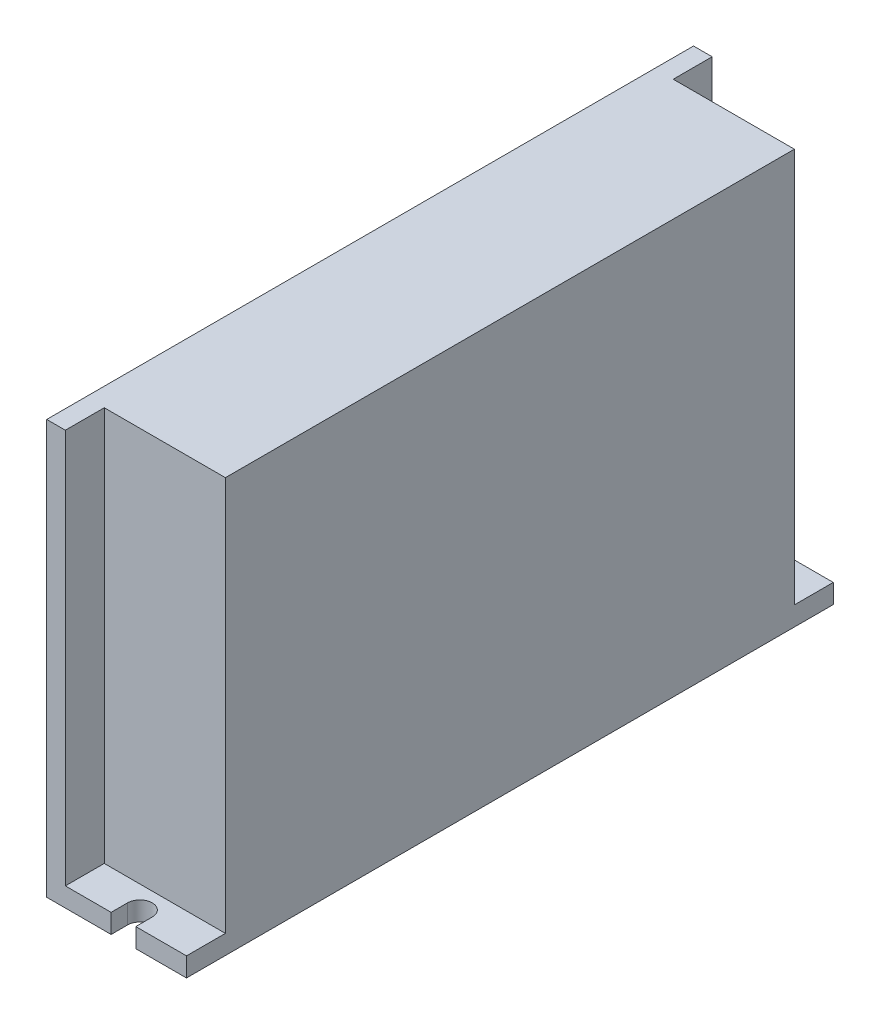
from build123d import *

# Parameters (mm, degrees)
SKETCH2_W           = 25.5
SKETCH2_H           = 118
BOSS_EXTRUDE3_DEPTH = 3.5
CUT_EXTRUDE1_DEPTH  = 4.5
SKETCH4_W           = 3.4
SKETCH4_H           = 118
BOSS_EXTRUDE4_DEPTH = 72
SKETCH5_W           = 22.1
SKETCH5_H           = 103.8
BOSS_EXTRUDE5_DEPTH = 72


with BuildPart() as part:
    # Sketch2 → Boss-Extrude3 (new body)
    with BuildSketch(Plane(origin=(0, 0, 0), x_dir=(1, 0, 0), z_dir=(0, 1, 0))):
        Rectangle(SKETCH2_W, SKETCH2_H)
    extrude(amount=BOSS_EXTRUDE3_DEPTH)

    # Sketch3 → Cut-Extrude1 (cut, through all)
    with BuildSketch(Plane(origin=(0, 3.5, 0), x_dir=(1, 0, 0), z_dir=(0, 1, 0))):
        with BuildLine():
            Line((-1, 56), (-1, 59))
            Line((-1, 59), (3.5, 59))
            Line((3.5, 59), (3.5, 56))
            ThreePointArc((3.5, 56), (1.25, 53.75), (-1, 56))
        make_face()
        with BuildLine():
            Line((-1, -56), (-1, -59))
            Line((-1, -59), (3.5, -59))
            Line((3.5, -59), (3.5, -56))
            ThreePointArc((3.5, -56), (1.25, -53.75), (-1, -56))
        make_face()
    extrude(amount=-CUT_EXTRUDE1_DEPTH, mode=Mode.SUBTRACT)

    # Sketch4 → Boss-Extrude4 (add)
    with BuildSketch(Plane(origin=(0, 3.5, 0), x_dir=(1, 0, 0), z_dir=(0, 1, 0))):
        with Locations((-11.05, 0)):
            Rectangle(SKETCH4_W, SKETCH4_H)
    extrude(amount=BOSS_EXTRUDE4_DEPTH)

    # Sketch5 → Boss-Extrude5 (add)
    with BuildSketch(Plane(origin=(0, 3.5, 0), x_dir=(1, 0, 0), z_dir=(0, 1, 0))):
        with Locations((1.7, 0)):
            Rectangle(SKETCH5_W, SKETCH5_H)
    extrude(amount=BOSS_EXTRUDE5_DEPTH)


solid = part.part
